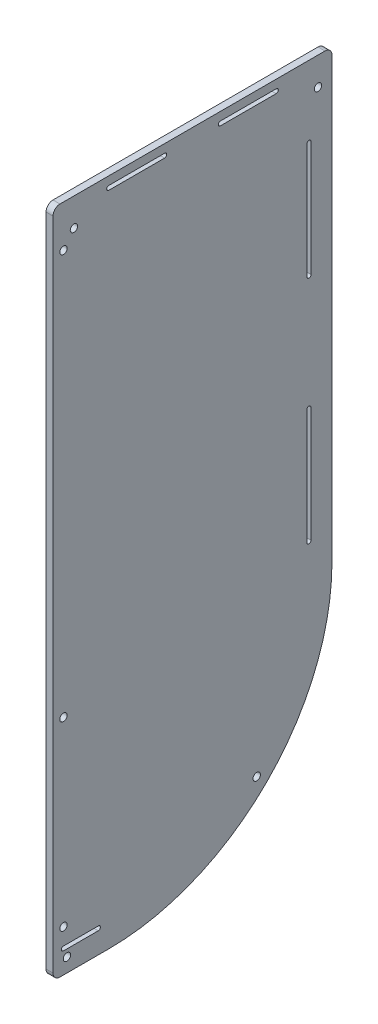
from build123d import *

# Parameters (mm, degrees)
BOSS_EXTRUDE1_DEPTH     = 6.35
SKETCH2_R               = 3.3655
CUT_EXTRUDE1_DEPTH      = 7.35
FILLET1_R               = 6.35
CUT_EXTRUDE6_DEPTH      = 7.35
SKETCH4_R               = 3.3655
CUT_EXTRUDE3_DEPTH      = 7.35
CUT_EXTRUDE7_DEPTH      = 7.35
CUT_EXTRUDE8_DEPTH      = 1
CUT_EXTRUDE8_DEPTH_BACK = 7.35


with BuildPart() as part:
    # Sketch1 → Boss-Extrude1 (new body)
    with BuildSketch(Plane(origin=(0, 0, 0), x_dir=(0, 0, -1), z_dir=(1, 0, 0))):
        with BuildLine():
            Line((0, 0), (0, -609.6))
            Line((0, -609.6), (50.8, -609.6))
            ThreePointArc((50.8, -609.6), (194.484097937, -550.084097937), (254, -406.4))
            Line((254, -406.4), (254, 0))
            Line((254, 0), (0, 0))
        make_face()
    extrude(amount=BOSS_EXTRUDE1_DEPTH)

    # Sketch2 → Cut-Extrude1 (cut, through all)
    with BuildSketch(Plane(origin=(6.35, 0, 0), x_dir=(0, 0, -1), z_dir=(1, 0, 0))):
        with Locations((241.3, -25.4)):
            Circle(SKETCH2_R)
        with Locations((12.7, -596.9)):
            Circle(SKETCH2_R)
        with Locations((185.503841816, -541.103841816)):
            Circle(SKETCH2_R)
        with Locations((19.05, -25.4)):
            Circle(SKETCH2_R)
    extrude(amount=-CUT_EXTRUDE1_DEPTH, mode=Mode.SUBTRACT)

    # Fillet1
    fillet1_edges = [part.edges().sort_by_distance(p)[0] for p in [
        (3.175, 0, -254),
        (3.175, -609.6, 0),
        (3.175, 0, 0),
    ]]
    fillet(fillet1_edges, radius=FILLET1_R)

    # Sketch3 → Cut-Extrude6 (cut, through all)
    with BuildSketch(Plane(origin=(6.35, 0, 0), x_dir=(0, 0, -1), z_dir=(1, 0, 0))):
        with BuildLine():
            Line((50.8, -7.62), (101.6, -7.62))
            ThreePointArc((101.6, -7.62), (103.505, -9.525), (101.6, -11.43))
            Line((101.6, -11.43), (50.8, -11.43))
            ThreePointArc((50.8, -11.43), (48.895, -9.525), (50.8, -7.62))
        make_face()
        with BuildLine():
            Line((152.4, -7.62), (203.2, -7.62))
            ThreePointArc((203.2, -7.62), (205.105, -9.525), (203.2, -11.43))
            Line((203.2, -11.43), (152.4, -11.43))
            ThreePointArc((152.4, -11.43), (150.495, -9.525), (152.4, -7.62))
        make_face()
    extrude(amount=-CUT_EXTRUDE6_DEPTH, mode=Mode.SUBTRACT)

    # Sketch4 → Cut-Extrude3 (cut, through all)
    with BuildSketch(Plane(origin=(6.35, 0, 0), x_dir=(0, 0, -1), z_dir=(1, 0, 0))):
        with Locations((9.525, -38.1)):
            Circle(SKETCH4_R)
        with Locations((9.525, -406.4)):
            Circle(SKETCH4_R)
        with Locations((9.525, -571.5)):
            Circle(SKETCH4_R)
    extrude(amount=-CUT_EXTRUDE3_DEPTH, mode=Mode.SUBTRACT)

    # Sketch6 → Cut-Extrude7 (cut, through all)
    with BuildSketch(Plane(origin=(6.35, 0, 0), x_dir=(0, 0, -1), z_dir=(1, 0, 0))):
        with BuildLine():
            Line((234.95, -65.0875), (234.95, -169.8625))
            ThreePointArc((234.95, -169.8625), (233.045, -171.7675), (231.14, -169.8625))
            Line((231.14, -169.8625), (231.14, -65.0875))
            ThreePointArc((231.14, -65.0875), (233.045, -63.1825), (234.95, -65.0875))
        make_face()
        with BuildLine():
            Line((231.14, -379.4125), (231.14, -274.6375))
            ThreePointArc((231.14, -274.6375), (233.045, -272.7325), (234.95, -274.6375))
            Line((234.95, -274.6375), (234.95, -379.4125))
            ThreePointArc((234.95, -379.4125), (233.045, -381.3175), (231.14, -379.4125))
        make_face()
    extrude(amount=-CUT_EXTRUDE7_DEPTH, mode=Mode.SUBTRACT)

    # Sketch7 → Cut-Extrude8 (cut, two sides)
    with BuildSketch(Plane(origin=(6.35, 0, 0), x_dir=(0, 0, -1), z_dir=(1, 0, 0))) as cut_extrude8_sk:
        with BuildLine():
            Line((9.525, -586.74), (41.275, -586.74))
            ThreePointArc((41.275, -586.74), (43.18, -588.645), (41.275, -590.55))
            Line((41.275, -590.55), (9.525, -590.55))
            ThreePointArc((9.525, -590.55), (7.62, -588.645), (9.525, -586.74))
        make_face()
    extrude(amount=CUT_EXTRUDE8_DEPTH, mode=Mode.SUBTRACT)
    extrude(cut_extrude8_sk.sketch, amount=-CUT_EXTRUDE8_DEPTH_BACK, mode=Mode.SUBTRACT)


solid = part.part
